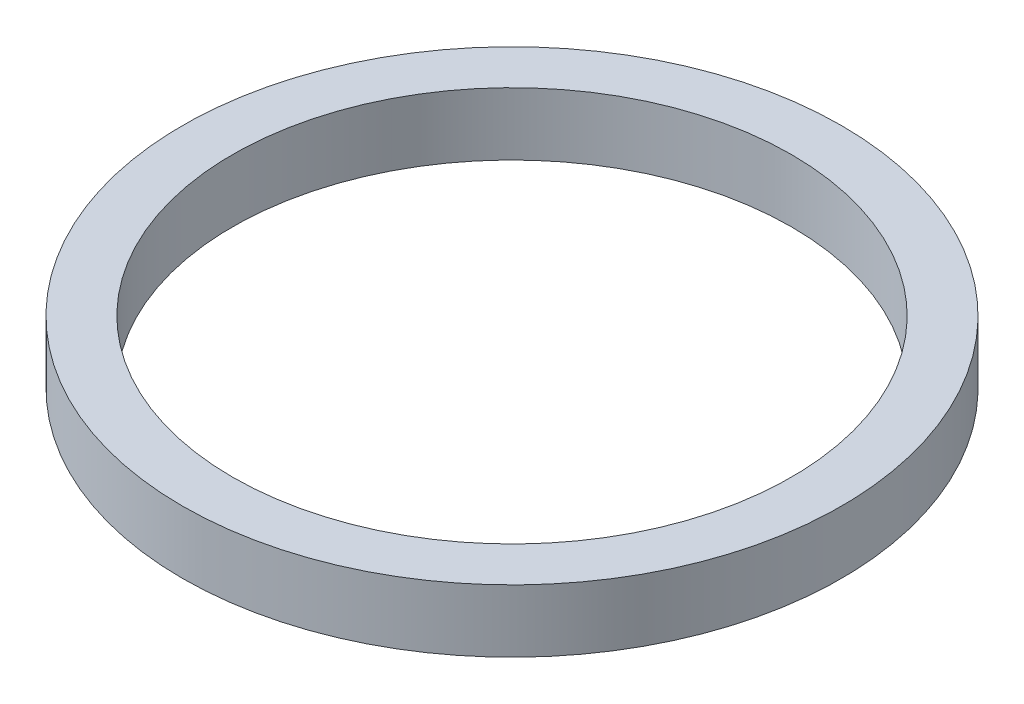
from build123d import *

# Parameters (mm, degrees)
SKETCH1_W = 2.54
SKETCH1_H = 3.175


with BuildPart() as part:
    # Sketch1 → Revolve1 (revolve)
    with BuildSketch(Plane.XY):
        with Locations((-15.4305, 0)):
            Rectangle(SKETCH1_W, SKETCH1_H)
    revolve(axis=Axis((0, 0, 0), (0, 1, 0)))


solid = part.part
